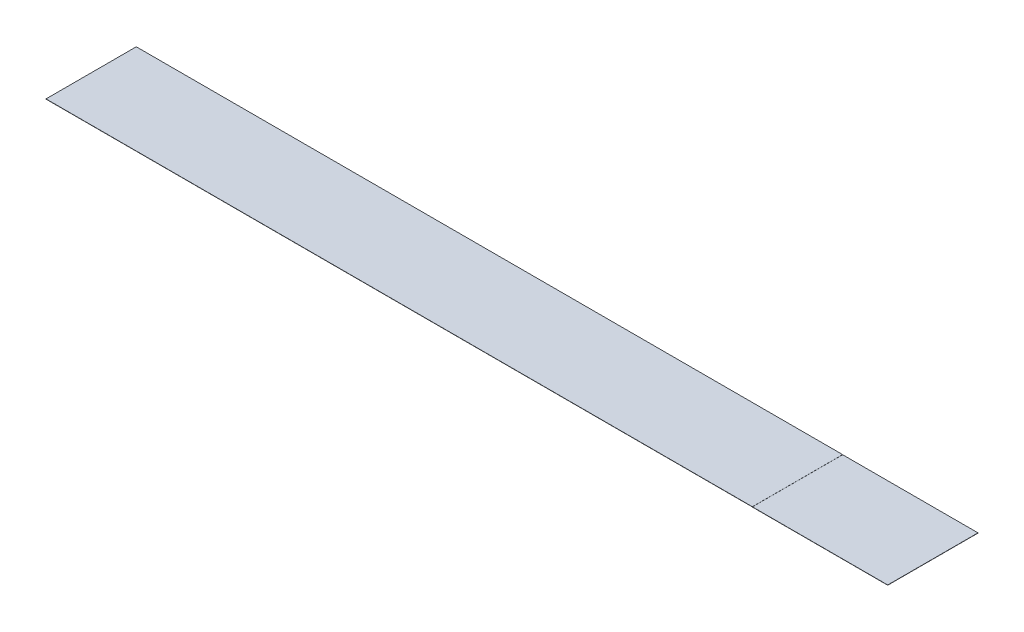
from build123d import *

# Parameters (mm, degrees)
SKETCH1_W           = 528.8
SKETCH1_H           = 61
EXTRUDE1_DEPTH      = 0.15
SKETCH3_W           = 20
SKETCH3_H           = 61
BOSS_EXTRUDE2_DEPTH = 0.15
SKETCH4_W           = 91.45
SKETCH4_H           = 0.06858
BOSS_EXTRUDE3_DEPTH = 61
SKETCH5_W           = 91.45
SKETCH5_H           = 0.06858
CUT_EXTRUDE1_DEPTH  = 62


with BuildPart() as part:
    # Sketch1 → Extrude1 (new body)
    with BuildSketch(Plane(origin=(0, 0, 0), x_dir=(1, 0, 0), z_dir=(0, 1, 0))):
        Rectangle(SKETCH1_W, SKETCH1_H)
    extrude(amount=EXTRUDE1_DEPTH)

    # Sketch3 → Boss-Extrude2 (add)
    with BuildSketch(Plane(origin=(0, 0.15, 0), x_dir=(1, 0, 0), z_dir=(0, 1, 0))):
        with Locations((-274.4, 0)):
            Rectangle(SKETCH3_W, SKETCH3_H)
        with Locations((274.4, 0)):
            Rectangle(SKETCH3_W, SKETCH3_H)
    extrude(amount=-BOSS_EXTRUDE2_DEPTH)

    # Sketch4 → Boss-Extrude3 (add)
    with BuildSketch(Plane.XY.offset(30.5)):
        with Locations((238.675, -0.03429)):
            Rectangle(SKETCH4_W, SKETCH4_H)
    extrude(amount=-BOSS_EXTRUDE3_DEPTH)

    # Sketch5 → Cut-Extrude1 (cut, through all)
    with BuildSketch(Plane(origin=(0, 0, -30.5), x_dir=(-1, 0, 0), z_dir=(0, 0, -1))):
        with Locations((-238.675, 0.11571)):
            Rectangle(SKETCH5_W, SKETCH5_H)
    extrude(amount=-CUT_EXTRUDE1_DEPTH, mode=Mode.SUBTRACT)


solid = part.part
